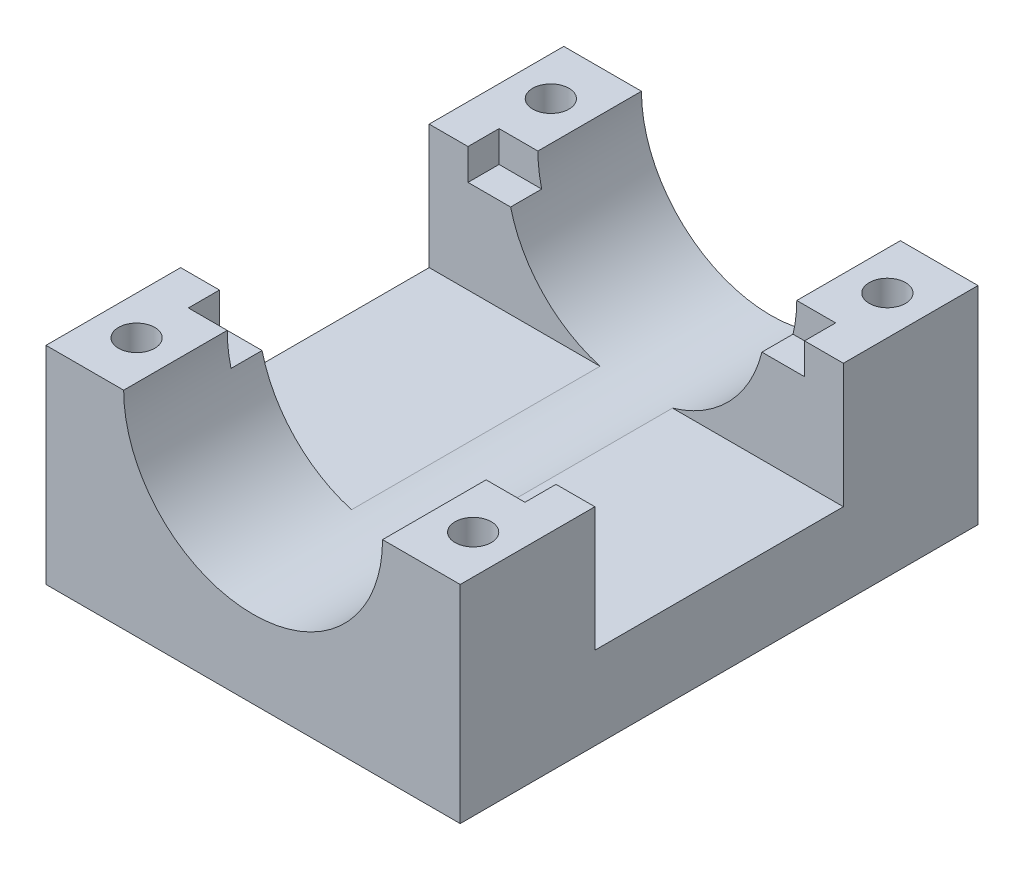
from build123d import *

# Parameters (mm, degrees)
CROQUIS1_W              = 40
CROQUIS1_H              = 50
SALIENTE_EXTRUIR1_DEPTH = 20
CROQUIS2_R              = 12.5
CORTAR_EXTRUIR1_DEPTH   = 51
CROQUIS3_R              = 1.75
CORTAR_EXTRUIR2_DEPTH   = 21
CORTAR_EXTRUIR3_DEPTH   = 41
CROQUIS5_W              = 5
CROQUIS5_H              = 3
CORTAR_EXTRUIR4_DEPTH   = 3


with BuildPart() as part:
    # Croquis1 → Saliente-Extruir1 (new body)
    with BuildSketch(Plane(origin=(0, 0, 0), x_dir=(1, 0, 0), z_dir=(0, 1, 0))):
        with Locations((20, 25)):
            Rectangle(CROQUIS1_W, CROQUIS1_H)
    extrude(amount=SALIENTE_EXTRUIR1_DEPTH)

    # Croquis2 → Cortar-Extruir1 (cut, through all)
    with BuildSketch(Plane.XY):
        with Locations((20, 20)):
            Circle(CROQUIS2_R)
    extrude(amount=-CORTAR_EXTRUIR1_DEPTH, mode=Mode.SUBTRACT)

    # Croquis3 → Cortar-Extruir2 (cut, through all)
    with BuildSketch(Plane(origin=(0, 20, 0), x_dir=(1, 0, 0), z_dir=(0, 1, 0))):
        with Locations((3.75, 45)):
            Circle(CROQUIS3_R)
        with Locations((36.25, 45)):
            Circle(CROQUIS3_R)
        with Locations((36.25, 5)):
            Circle(CROQUIS3_R)
        with Locations((3.75, 5)):
            Circle(CROQUIS3_R)
    extrude(amount=-CORTAR_EXTRUIR2_DEPTH, mode=Mode.SUBTRACT)

    # Croquis4 → Cortar-Extruir3 (cut, through all)
    with BuildSketch(Plane(origin=(40, 0, 0), x_dir=(0, 0, -1), z_dir=(1, 0, 0))):
        Polygon((25, 20), (37, 20), (37, 8), (13, 8), (13, 20), align=None)
    extrude(amount=-CORTAR_EXTRUIR3_DEPTH, mode=Mode.SUBTRACT)

    # Croquis5 → Cortar-Extruir4 (cut)
    with BuildSketch(Plane(origin=(0, 20, 0), x_dir=(1, 0, 0), z_dir=(0, 1, 0))):
        with Locations((6.25, 38.5)):
            Rectangle(CROQUIS5_W, CROQUIS5_H)
        with Locations((33.75, 38.5)):
            Rectangle(CROQUIS5_W, CROQUIS5_H)
        with Locations((33.75, 11.5)):
            Rectangle(CROQUIS5_W, CROQUIS5_H)
        with Locations((6.25, 11.5)):
            Rectangle(CROQUIS5_W, CROQUIS5_H)
    extrude(amount=-CORTAR_EXTRUIR4_DEPTH, mode=Mode.SUBTRACT)


solid = part.part
